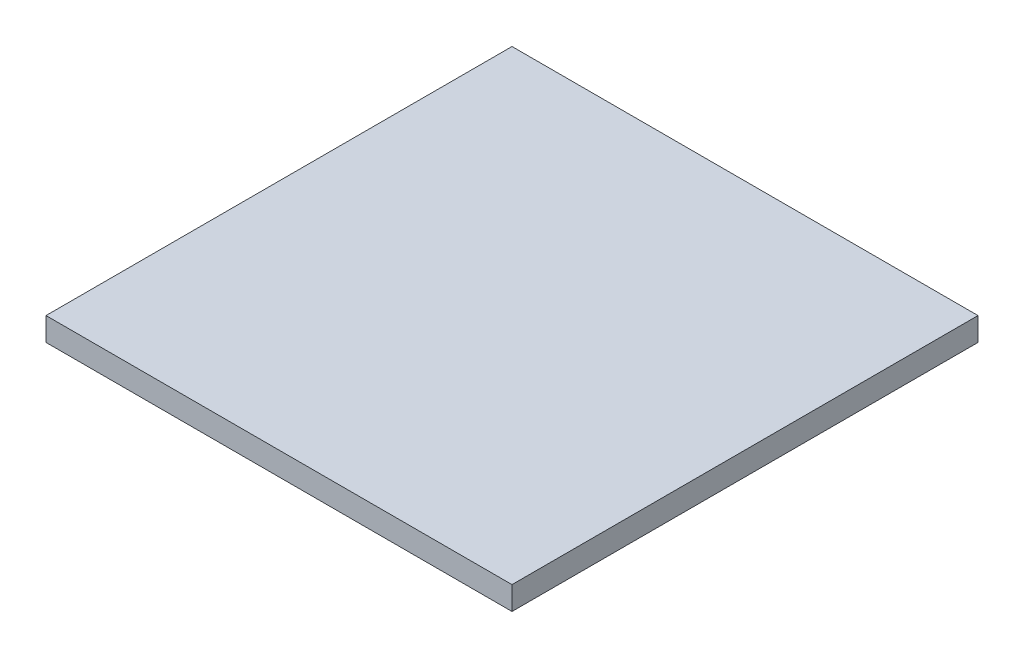
from build123d import *

# Parameters (mm, degrees)
SKETCH2_W           = 20
SKETCH2_H           = 20
BOSS_EXTRUDE1_DEPTH = 1


with BuildPart() as part:
    # Sketch2 → Boss-Extrude1 (new body)
    with BuildSketch(Plane(origin=(0, 0, 0), x_dir=(1, 0, 0), z_dir=(0, 1, 0))):
        with Locations((-8.629406909, 1.940192695)):
            Rectangle(SKETCH2_W, SKETCH2_H)
    extrude(amount=BOSS_EXTRUDE1_DEPTH)


solid = part.part
